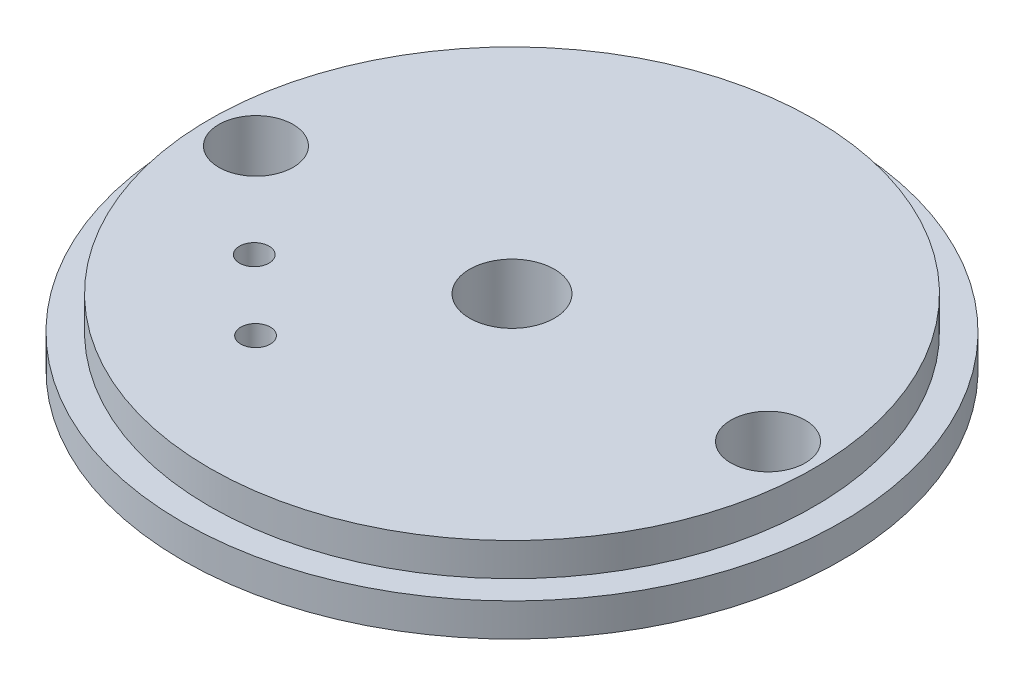
from build123d import *

# Parameters (mm, degrees)
SKETCH1_R                   = 25.3365
BOSS_EXTRUDE1_DEPTH         = 2.54
SKETCH2_R                   = 23.241
BOSS_EXTRUDE2_DEPTH         = 2.54
F_1_4_CLEARANCE_HOLE1_D     = 6.5278
F_1_4_CLEARANCE_HOLE1_DEPTH = 5.08
CUT_EXTRUDE1_REACH          = 7.08
SKETCH5_R                   = 2.8575
CUT_EXTRUDE2_REACH          = 7.08
SKETCH6_R                   = 1.136382046


with BuildPart() as part:
    # Sketch1 → Boss-Extrude1 (new body)
    with BuildSketch(Plane(origin=(0, 0, 0), x_dir=(1, 0, 0), z_dir=(0, 1, 0))):
        Circle(SKETCH1_R)
    extrude(amount=BOSS_EXTRUDE1_DEPTH)

    # Sketch2 → Boss-Extrude2 (add)
    with BuildSketch(Plane(origin=(0, 2.54, 0), x_dir=(1, 0, 0), z_dir=(0, 1, 0))):
        Circle(SKETCH2_R)
    extrude(amount=BOSS_EXTRUDE2_DEPTH)

    # 1/4 Clearance Hole1
    with Locations(Plane.XZ):
        with Locations((0, 0)):
            Hole(F_1_4_CLEARANCE_HOLE1_D / 2, depth=F_1_4_CLEARANCE_HOLE1_DEPTH)

    # Sketch5 → Cut-Extrude1 (cut, up to next)
    with BuildSketch(Plane.XZ, mode=Mode.PRIVATE) as cut_extrude1_sk1:
        with Locations((-19.685, 0)):
            Circle(SKETCH5_R)
    cut_extrude1_tool1 = extrude(cut_extrude1_sk1.sketch, amount=-CUT_EXTRUDE1_REACH, mode=Mode.PRIVATE) & part.part
    add(cut_extrude1_tool1.solids().sort_by_distance((-19.685, 0, 0))[0], mode=Mode.SUBTRACT)
    # Sketch5 → Cut-Extrude1 (cut, up to next)
    with BuildSketch(Plane.XZ, mode=Mode.PRIVATE) as cut_extrude1_sk2:
        with Locations((19.685, 0)):
            Circle(SKETCH5_R)
    cut_extrude1_tool2 = extrude(cut_extrude1_sk2.sketch, amount=-CUT_EXTRUDE1_REACH, mode=Mode.PRIVATE) & part.part
    add(cut_extrude1_tool2.solids().sort_by_distance((19.685, 0, 0))[0], mode=Mode.SUBTRACT)

    # Sketch6 → Cut-Extrude2 (cut, up to next)
    with BuildSketch(Plane.XZ, mode=Mode.PRIVATE) as cut_extrude2_sk1:
        with Locations((-7.069885154, 12.643721498)):
            Circle(SKETCH6_R)
    cut_extrude2_tool1 = extrude(cut_extrude2_sk1.sketch, amount=-CUT_EXTRUDE2_REACH, mode=Mode.PRIVATE) & part.part
    add(cut_extrude2_tool1.solids().sort_by_distance((-7.069885, 0, 12.643721))[0], mode=Mode.SUBTRACT)
    # Sketch6 → Cut-Extrude2 (cut, up to next)
    with BuildSketch(Plane.XZ, mode=Mode.PRIVATE) as cut_extrude2_sk2:
        with Locations((-12.50848412, 7.306489885)):
            Circle(SKETCH6_R)
    cut_extrude2_tool2 = extrude(cut_extrude2_sk2.sketch, amount=-CUT_EXTRUDE2_REACH, mode=Mode.PRIVATE) & part.part
    add(cut_extrude2_tool2.solids().sort_by_distance((-12.508484, 0, 7.30649))[0], mode=Mode.SUBTRACT)


solid = part.part
